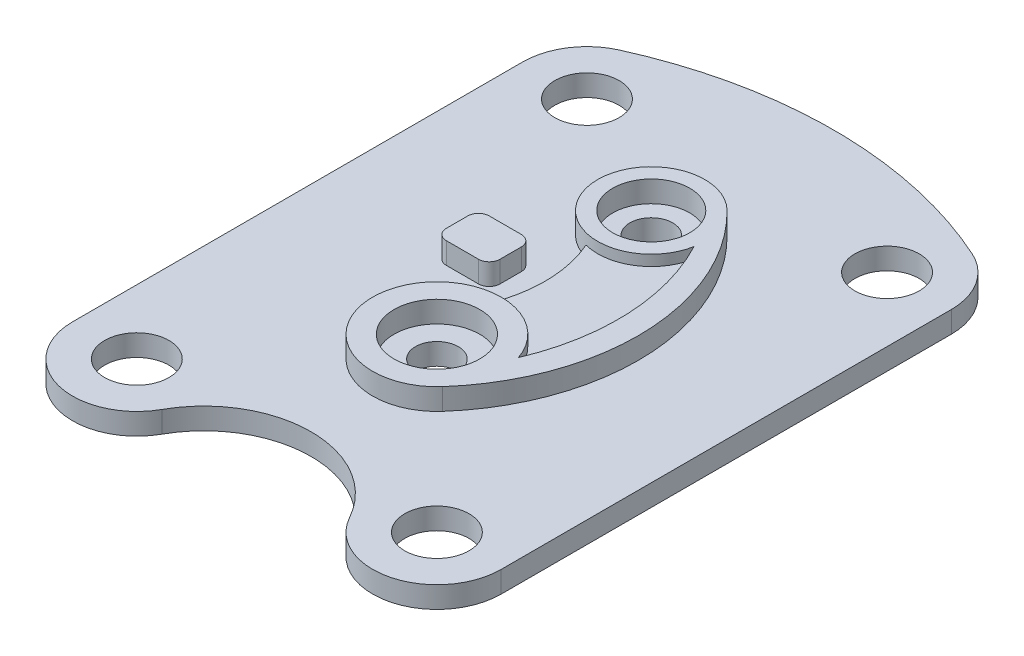
from build123d import *

# Parameters (mm, degrees)
SKETCH1_R           = 15
SKETCH1_R_2         = 10
BOSS_EXTRUDE1_DEPTH = 10
SKETCH1_3_R         = 20
SKETCH1_3_R_2       = 18
BOSS_EXTRUDE2_DEPTH = 20
BOSS_EXTRUDE3_DEPTH = 15


with BuildPart() as part:
    # Sketch1 → Boss-Extrude1 (new body)
    with BuildSketch(Plane(origin=(0, 0, 0), x_dir=(1, 0, 0), z_dir=(0, 1, 0))):
        with BuildLine():
            Line((-100, 105), (-100, -105))
            ThreePointArc((-100, -105), (-77.5, -134.047375097), (-43.75, -119.523687548))
            ThreePointArc((-43.75, -119.523687548), (0, -93.729833462), (43.75, -119.523687548))
            ThreePointArc((43.75, -119.523687548), (77.5, -134.047375097), (100, -105))
            Line((100, -105), (100, 105))
            ThreePointArc((100, 105), (95.205041513, 121.269784336), (82.352941176, 132.338705973))
            ThreePointArc((82.352941176, 132.338705973), (0, 150.080666152), (-82.352941176, 132.338705973))
            ThreePointArc((-82.352941176, 132.338705973), (-95.205041513, 121.269784336), (-100, 105))
        make_face()
        with Locations((-70, 105)):
            Circle(SKETCH1_R, mode=Mode.SUBTRACT)
        with Locations((-70, -105)):
            Circle(SKETCH1_R, mode=Mode.SUBTRACT)
        with Locations((70, 105)):
            Circle(SKETCH1_R, mode=Mode.SUBTRACT)
        with Locations((70, -105)):
            Circle(SKETCH1_R, mode=Mode.SUBTRACT)
        with Locations((0, -35)):
            Circle(SKETCH1_R_2, mode=Mode.SUBTRACT)
        with Locations((0, 65)):
            Circle(SKETCH1_R_2, mode=Mode.SUBTRACT)
    extrude(amount=BOSS_EXTRUDE1_DEPTH)

    # Sketch1_3 → Boss-Extrude2 (add)
    # profile 1 of 2: a face of its own
    with BuildSketch(Plane(origin=(0, 0, 0), x_dir=(1, 0, 0), z_dir=(0, 1, 0))):
        with BuildLine():
            ThreePointArc((-40.589236585, 10), (-39.124770491, 6.464466094), (-35.589236585, 5))
            Line((-35.589236585, 5), (-20.589236585, 5))
            ThreePointArc((-20.589236585, 5), (-17.053702679, 6.464466094), (-15.589236585, 10))
            Line((-15.589236585, 10), (-15.589236585, 20))
            ThreePointArc((-15.589236585, 20), (-17.053702679, 23.535533906), (-20.589236585, 25))
            Line((-20.589236585, 25), (-35.589236585, 25))
            ThreePointArc((-35.589236585, 25), (-39.124770491, 23.535533906), (-40.589236585, 20))
            Line((-40.589236585, 20), (-40.589236585, 10))
        make_face()
    # profile 2 of 2: a face of its own
    with BuildSketch(Plane(origin=(0, 0, 0), x_dir=(1, 0, 0), z_dir=(0, 1, 0))):
        with BuildLine():
            ThreePointArc((28.439679063, -25.450934351), (-29.401361297, -29.036783258), (22.4718574, -54.875))
            ThreePointArc((22.4718574, -54.875), (47.50001952, 14.997844187), (17.478111311, 82.875))
            ThreePointArc((17.478111311, 82.875), (-23.846726615, 57.494426755), (24.565221674, 60.357814729))
            ThreePointArc((24.565221674, 60.357814729), (36.184989958, 17.890628558), (28.439679063, -25.450934351))
        make_face()
        with Locations((0, -35)):
            Circle(SKETCH1_3_R, mode=Mode.SUBTRACT)
        with Locations((0, 65)):
            Circle(SKETCH1_3_R_2, mode=Mode.SUBTRACT)
    extrude(amount=BOSS_EXTRUDE2_DEPTH)

    # Sketch1_4 → Boss-Extrude3 (add)
    with BuildSketch(Plane(origin=(0, 0, 0), x_dir=(1, 0, 0), z_dir=(0, 1, 0))):
        with BuildLine():
            ThreePointArc((-6.254967912, 40.795137339), (-1.162830862, 17.74699723), (-5.354714274, -5.481750813))
            ThreePointArc((-5.354714274, -5.481750813), (15.261748675, -9.172126929), (28.439679063, -25.450934351))
            ThreePointArc((28.439679063, -25.450934351), (36.184989958, 17.890628558), (24.565221674, 60.357814729))
            ThreePointArc((24.565221674, 60.357814729), (13.397422695, 43.892914338), (-6.254967912, 40.795137339))
        make_face()
    extrude(amount=BOSS_EXTRUDE3_DEPTH)


solid = part.part
